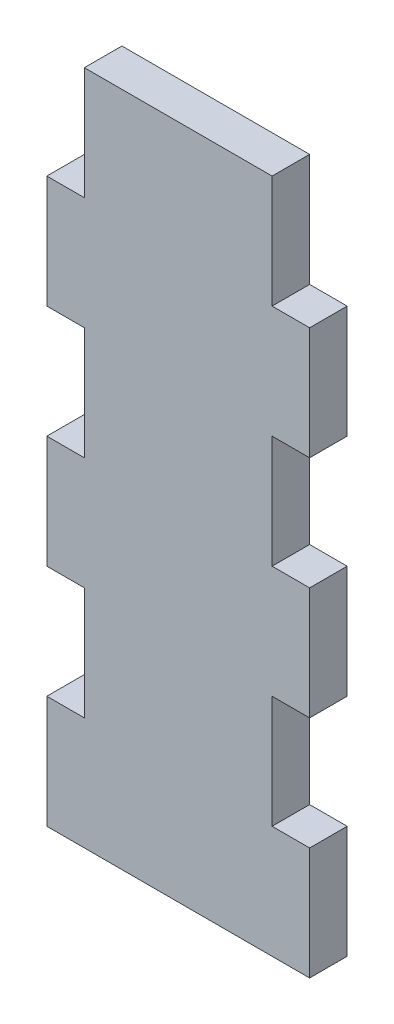
from build123d import *

# Parameters (mm, degrees)
BOSS_EXTRUDE1_DEPTH = 6


with BuildPart() as part:
    # Model → Boss-Extrude1 (new body)
    with BuildSketch(Plane.XY):
        Polygon((25.499387766, 117.749022314), (25.499387766, 99.749022314), (19.499387766, 99.749022314), (19.499387766, 81.749022314), (25.499387766, 81.749022314), (25.499387766, 63.749022314), (19.499387766, 63.749022314), (19.499387766, 45.749022314), (25.499387766, 45.749022314), (25.499387766, 27.749022314), (19.499387766, 27.749022314), (19.499387766, 9.749022314), (61.499387766, 9.749022314), (61.499387766, 27.749022314), (55.499387766, 27.749022314), (55.499387766, 45.749022314), (61.499387766, 45.749022314), (61.499387766, 63.749022314), (55.499387766, 63.749022314), (55.499387766, 81.749022314), (61.499387766, 81.749022314), (61.499387766, 99.749022314), (55.499387766, 99.749022314), (55.499387766, 117.749022314), align=None)
    extrude(amount=BOSS_EXTRUDE1_DEPTH)


solid = part.part
